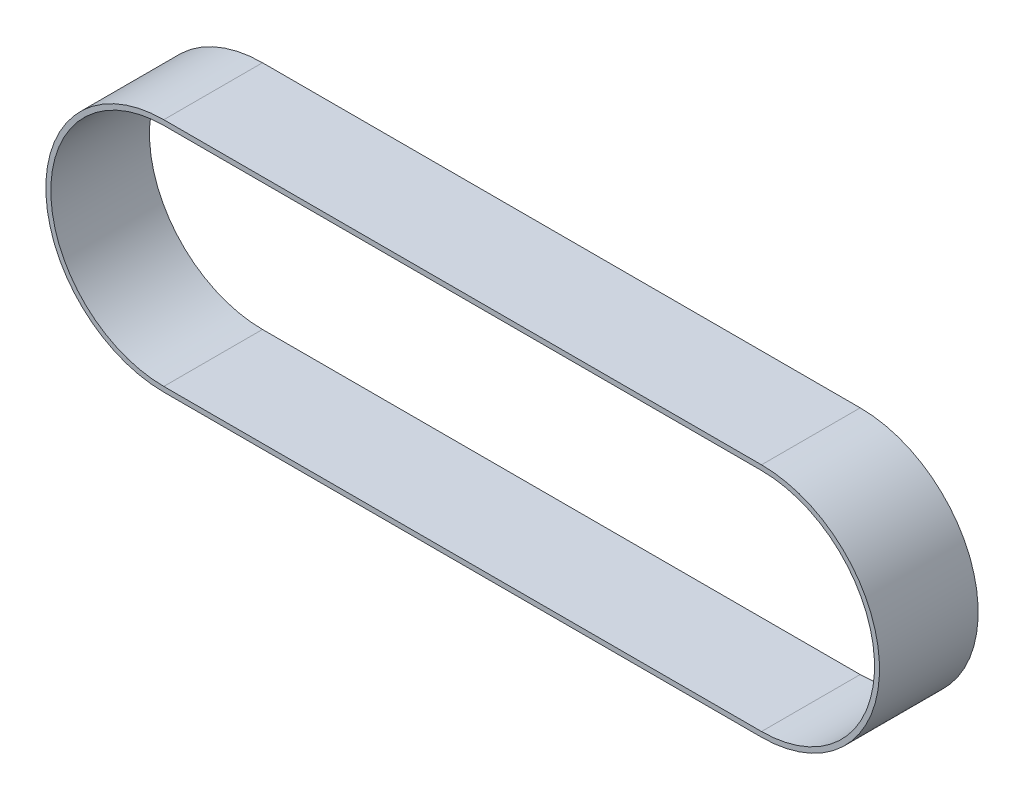
from build123d import *

# Parameters (mm, degrees)
BOSS_EXTRUDE1_DEPTH = 9.906


with BuildPart() as part:
    # Sketch1 → Boss-Extrude1 (new body, symmetric)
    with BuildSketch(Plane.XY):
        with BuildLine():
            Line((0, 46.3771), (120.015, 46.3771))
            ThreePointArc((120.015, 46.3771), (143.70355, 22.68855), (120.015, -1))
            Line((120.015, -1), (0, -1))
            ThreePointArc((0, -1), (-23.68855, 22.68855), (0, 46.3771))
        make_face()
        with BuildLine():
            Line((0, 45.3771), (120.015, 45.3771))
            ThreePointArc((120.015, 45.3771), (142.70355, 22.68855), (120.015, 0))
            Line((120.015, 0), (0, 0))
            ThreePointArc((0, 0), (-22.68855, 22.68855), (0, 45.3771))
        make_face(mode=Mode.SUBTRACT)
    extrude(amount=BOSS_EXTRUDE1_DEPTH, both=True)


solid = part.part
